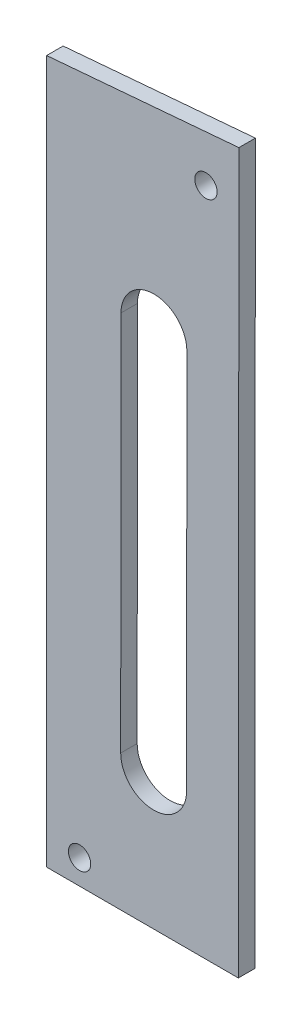
from build123d import *

# Parameters (mm, degrees)
BOSS_EXTRUDE1_DEPTH   = 3.175
F_6_CLEARANCE_HOLE1_D = 4.3053


with BuildPart() as part:
    # Sketch1 → Boss-Extrude1 (new body)
    with BuildSketch(Plane.XY):
        Polygon((866.156250481, 6490.011012461), (829.199261489, 6490.03953741), (829.199261489, 6625.537287847), (866.263292559, 6628.694971151), align=None)
        with BuildLine():
            Line((856.233206108, 6589.718701179), (856.176475752, 6516.218723072))
            ThreePointArc((856.176475752, 6516.218723072), (849.821576449, 6509.873626158), (843.476479535, 6516.22852546))
            Line((843.476479535, 6516.22852546), (843.533209891, 6589.728503567))
            ThreePointArc((843.533209891, 6589.728503567), (849.888109194, 6596.073600482), (856.233206108, 6589.718701179))
        make_face(mode=Mode.SUBTRACT)
    extrude(amount=BOSS_EXTRUDE1_DEPTH)

    # #6 Clearance Hole1 (through all)
    with Locations(Plane.XY.offset(3.175)):
        with Locations((859.90595224, 6619.187287847), (835.549261489, 6494.797137633)):
            Hole(F_6_CLEARANCE_HOLE1_D / 2)


solid = part.part
